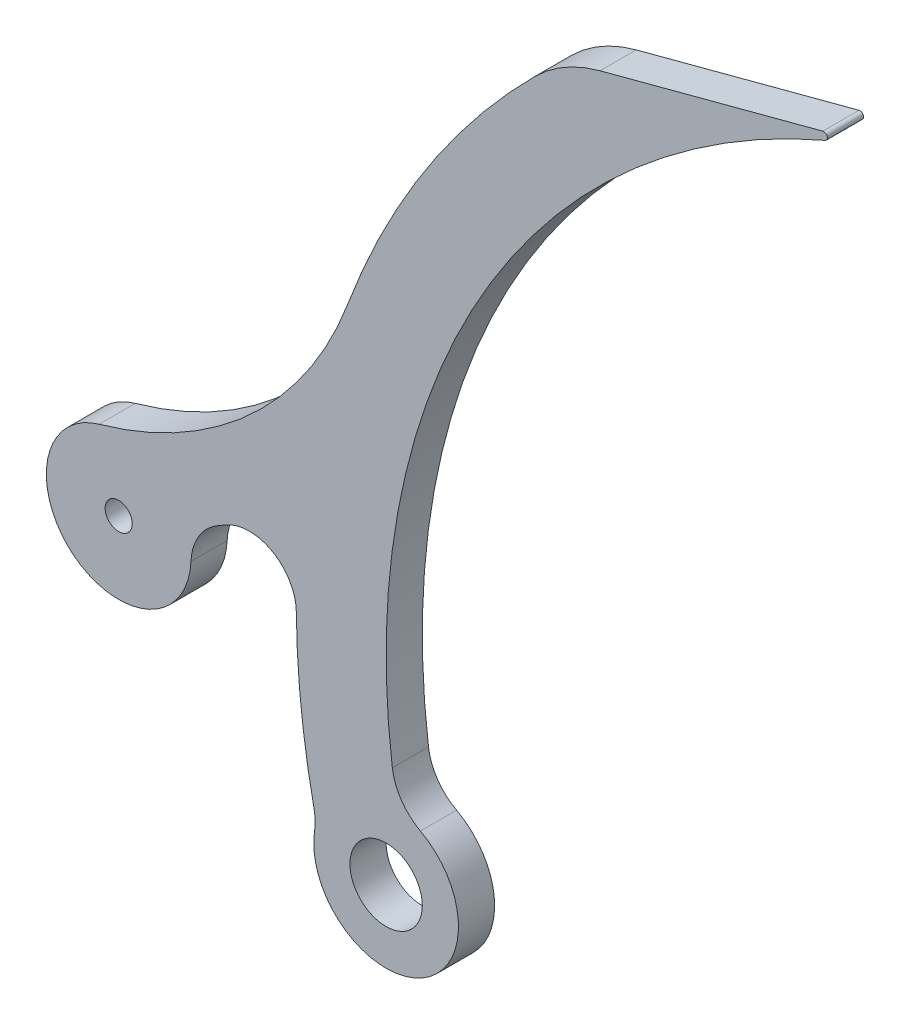
from build123d import *

# Parameters (mm, degrees)
SKETCH1_R           = 12.7
SKETCH1_R_2         = 4.7625
BOSS_EXTRUDE1_DEPTH = 12.7


with BuildPart() as part:
    # Sketch1 → Boss-Extrude1 (new body)
    with BuildSketch(Plane.XY):
        with BuildLine():
            Line((-187.814837627, 239.286832502), (-109.585986317, 260.040435914))
            ThreePointArc((-109.585986317, 260.040435914), (-108.059532137, 259.226405199), (-108.761135557, 257.645120591))
            ThreePointArc((-108.761135557, 257.645120591), (-229.615919323, 149.828924192), (-260.74357991, -9.109050224))
            ThreePointArc((-260.74357991, -9.109050224), (-257.535715145, -17.439529004), (-250.885068445, -23.394037509))
            ThreePointArc((-250.885068445, -23.394037509), (-251.565109459, -68.479908862), (-288.037537466, -41.966511367))
            ThreePointArc((-288.037537466, -41.966511367), (-287.832141181, -38.557969421), (-288.238569154, -35.167517809))
            ThreePointArc((-288.238569154, -35.167517809), (-292.752508854, -7.04544043), (-294.442288596, 21.386434854))
            ThreePointArc((-294.442288596, 21.386434854), (-302.842926447, 35.611738456), (-319.362594724, 35.436984704))
            ThreePointArc((-319.362594724, 35.436984704), (-320.58266827, 34.722082272), (-321.809158258, 34.018244753))
            ThreePointArc((-321.809158258, 34.018244753), (-328.648477907, 27.400808215), (-331.433346202, 18.300738536))
            ThreePointArc((-331.433346202, 18.300738536), (-372.60107774, -0.462072999), (-363.664476838, 43.888376615))
            ThreePointArc((-363.664476838, 43.888376615), (-310.417085479, 73.549005343), (-276.36661221, 124.101976107))
            ThreePointArc((-276.36661221, 124.101976107), (-249.008169348, 178.646013909), (-210.684679592, 226.131238859))
            ThreePointArc((-210.684679592, 226.131238859), (-200.118731843, 234.219669183), (-187.814837627, 239.286832502))
        make_face()
        with Locations((-262.922494985, -45.760538404)):
            Circle(SKETCH1_R, mode=Mode.SUBTRACT)
        with Locations((-356.808175222, 19.431248244)):
            Circle(SKETCH1_R_2, mode=Mode.SUBTRACT)
    extrude(amount=BOSS_EXTRUDE1_DEPTH)


solid = part.part
